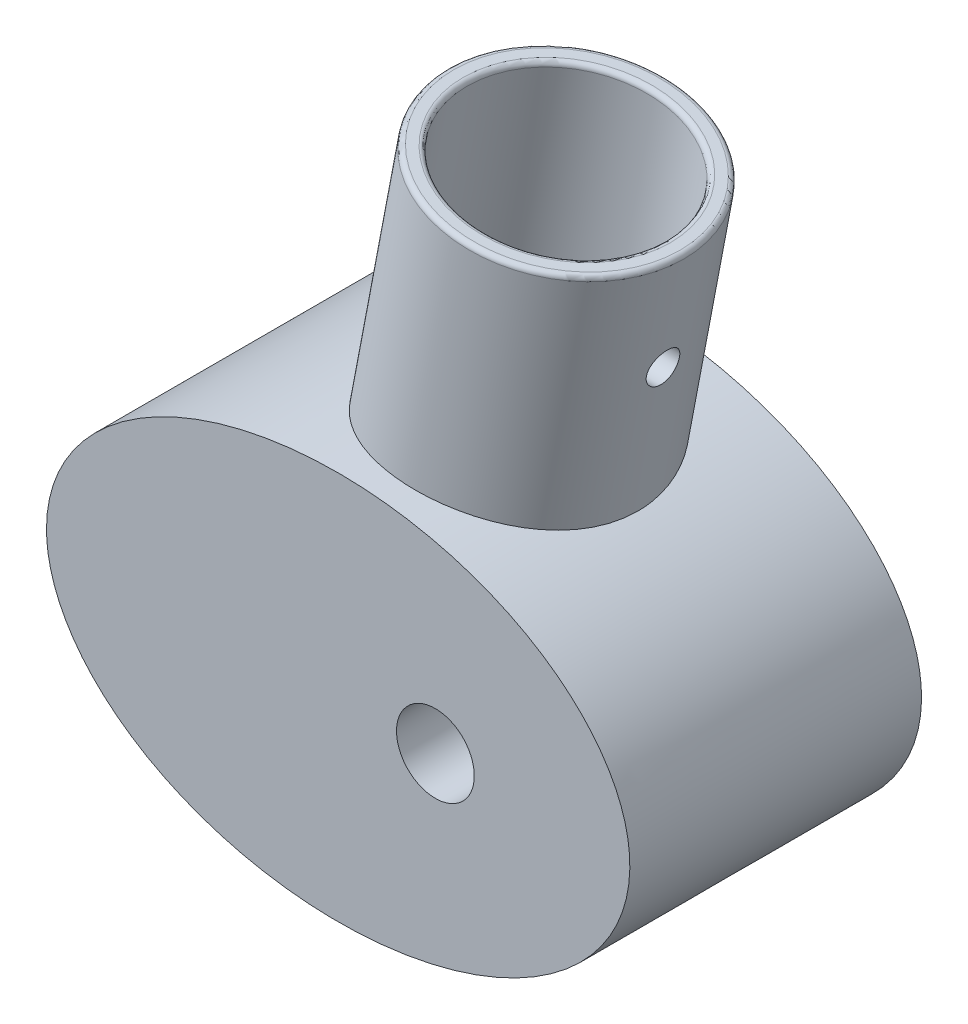
from build123d import *

# Parameters (mm, degrees)
SKETCH2_RX              = 30
SKETCH2_RY              = 20
BOSS_EXTRUDE1_DEPTH     = 30
CUT_EXTRUDE1_DEPTH      = 3
BOSS_EXTRUDE2_REACH     = 72.708
SKETCH7_R               = 12.35
SKETCH7_R_2             = 10.35
SKETCH8_RX              = 30
SKETCH8_RY              = 20
BOSS_EXTRUDE4_DEPTH     = 7.4
SKETCH12_R              = 1.7
CUT_EXTRUDE3_DEPTH      = 31.0000001
CUT_EXTRUDE3_DEPTH_BACK = 31.0000001
SKETCH13_R              = 4
CUT_EXTRUDE4_DEPTH      = 1.0000001
CUT_EXTRUDE4_DEPTH_BACK = 31.0000001
FILLET4_R               = 0.5


with BuildPart() as part:
    # Sketch2 → Boss-Extrude1 (new body)
    with BuildSketch(Plane.XY):
        with Locations(Location((10, 0), (0, 0, 0))):
            Ellipse(SKETCH2_RX, SKETCH2_RY)
        with BuildLine():
            Line((-3.398305936, 10.6), (7.0394788, 10.6))
            Line((7.0394788, 10.6), (29.1, 10.6))
            ThreePointArc((29.1, 10.6), (30.089949494, 10.189949494), (30.5, 9.2))
            Line((30.5, 9.2), (30.5, 1.15))
            Line((30.5, 1.15), (31.7, 1.15))
            Line((31.7, 1.15), (36.3, 1.15))
            Line((36.3, 1.15), (36.3, -1.15))
            Line((36.3, -1.15), (30.5, -1.15))
            Line((30.5, -1.15), (30.5, -9.2))
            ThreePointArc((30.5, -9.2), (30.089949494, -10.189949494), (29.1, -10.6))
            Line((29.1, -10.6), (7.0394788, -10.6))
            Line((7.0394788, -10.6), (-3.398305936, -10.6))
            Line((-3.398305936, -10.6), (-9.1, -10.6))
            ThreePointArc((-9.1, -10.6), (-10.089949494, -10.189949494), (-10.5, -9.2))
            Line((-10.5, -9.2), (-10.5, -1.15))
            Line((-10.5, -1.15), (-11.7, -1.15))
            Line((-11.7, -1.15), (-16.3, -1.15))
            Line((-16.3, -1.15), (-16.3, 1.15))
            Line((-16.3, 1.15), (-11.7, 1.15))
            Line((-11.7, 1.15), (-10.5, 1.15))
            Line((-10.5, 1.15), (-10.5, 9.2))
            ThreePointArc((-10.5, 9.2), (-10.089949494, 10.189949494), (-9.1, 10.6))
            Line((-9.1, 10.6), (-3.398305936, 10.6))
        make_face(mode=Mode.SUBTRACT)
    extrude(amount=BOSS_EXTRUDE1_DEPTH)

    # Sketch3 → Cut-Extrude1 (cut)
    with BuildSketch(Plane(origin=(0, 0, 0), x_dir=(-1, 0, 0), z_dir=(0, 0, -1))):
        with BuildLine():
            ThreePointArc((-35.95160583, -5.486111111), (-33.55, -5), (-35.95160583, -4.513888889))
            ThreePointArc((-35.95160583, -4.513888889), (-36.05, -5), (-35.95160583, -5.486111111))
        make_face()
        with BuildLine():
            ThreePointArc((-35.95160583, 4.513888889), (-33.55, 5), (-35.95160583, 5.486111111))
            ThreePointArc((-35.95160583, 5.486111111), (-36.05, 5), (-35.95160583, 4.513888889))
        make_face()
        with BuildLine():
            ThreePointArc((15.95160583, 5.486111111), (13.55, 5), (15.95160583, 4.513888889))
            ThreePointArc((15.95160583, 4.513888889), (16.05, 5), (15.95160583, 5.486111111))
        make_face()
        with BuildLine():
            ThreePointArc((15.95160583, -4.513888889), (13.55, -5), (15.95160583, -5.486111111))
            ThreePointArc((15.95160583, -5.486111111), (16.05, -5), (15.95160583, -4.513888889))
        make_face()
    extrude(amount=-CUT_EXTRUDE1_DEPTH, mode=Mode.SUBTRACT)

    # Sketch7 → Boss-Extrude2 (add, up to next)
    with BuildSketch(Plane(origin=(1.476165174, 44.628491235, 15), x_dir=(0.98224471, 0.187604184, 0), z_dir=(-0.187604184, 0.98224471, 0)), mode=Mode.PRIVATE) as boss_extrude2_sk1:
        Circle(SKETCH7_R)
        Circle(SKETCH7_R_2, mode=Mode.SUBTRACT)
    boss_extrude2_tool1 = extrude(boss_extrude2_sk1.sketch, amount=-BOSS_EXTRUDE2_REACH, mode=Mode.PRIVATE) - part.part
    add(boss_extrude2_tool1.solids().sort_by_distance((-10.311448, 42.377112, 15))[0])

    # Sketch8 → Boss-Extrude4 (add)
    with BuildSketch(Plane.XY.offset(30)):
        with Locations(Location((10, 0), (0, 0, 0))):
            Ellipse(SKETCH8_RX, SKETCH8_RY)
    extrude(amount=-BOSS_EXTRUDE4_DEPTH)

    # Sketch12 → Cut-Extrude3 (cut, two sides)
    with BuildSketch(Plane(origin=(10, -10, 0), x_dir=(0, 1, 0), z_dir=(-1, 0, 0))) as cut_extrude3_sk:
        with Locations((41.155789783, -15)):
            Circle(SKETCH12_R)
    extrude(amount=CUT_EXTRUDE3_DEPTH, mode=Mode.SUBTRACT)
    extrude(cut_extrude3_sk.sketch, amount=-CUT_EXTRUDE3_DEPTH_BACK, mode=Mode.SUBTRACT)

    # Sketch13 → Cut-Extrude4 (cut, two sides)
    with BuildSketch(Plane.XY.offset(30)) as cut_extrude4_sk:
        Circle(SKETCH13_R)
    extrude(amount=CUT_EXTRUDE4_DEPTH, mode=Mode.SUBTRACT)
    extrude(cut_extrude4_sk.sketch, amount=-CUT_EXTRUDE4_DEPTH_BACK, mode=Mode.SUBTRACT)


with BuildPart() as body_2:
    # Mirror1: mirrored copy
    add(part.part.mirror(Plane(origin=(-25, 0, 0), x_dir=(0, 0, 1), z_dir=(1, 0, 0))))

    # Fillet4
    fillet4_edges = [body_2.edges().sort_by_distance(p)[0] for p in [
        (-39.345443006, 42.311579567, 15),
        (-41.309932426, 42.686787934, 15),
    ]]
    fillet(fillet4_edges, radius=FILLET4_R)


solid = body_2.part
